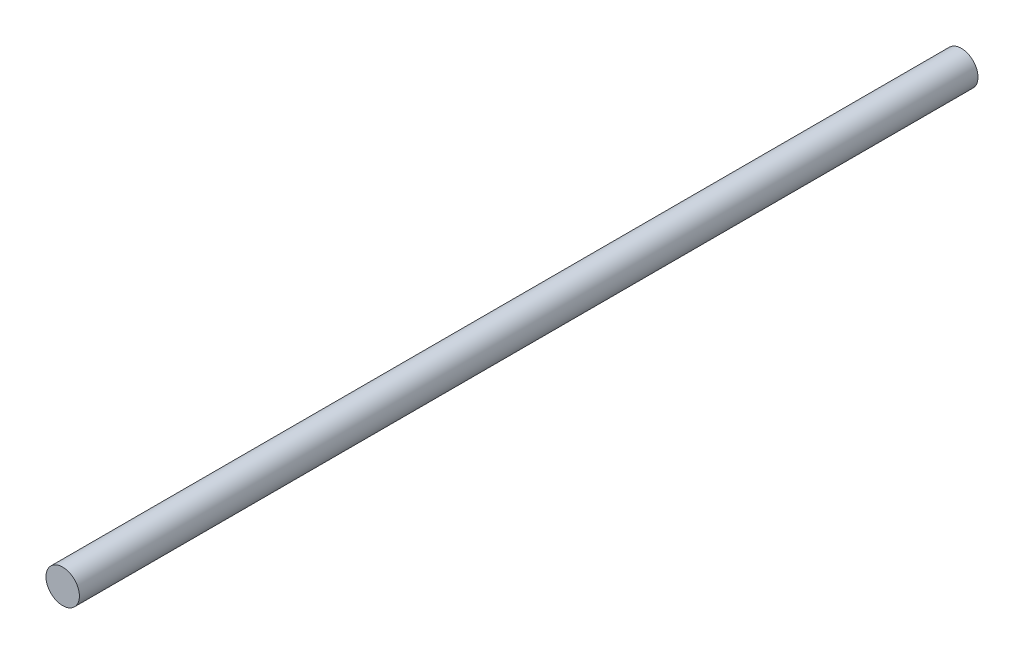
from build123d import *

# Parameters (mm, degrees)
SKETCH1_R                 = 4
BOSS_EXTRUDE1_DEPTH       = 215
M4X0_7_TAPPED_HOLE2_D     = 3.3
M4X0_7_TAPPED_HOLE2_DEPTH = 10.1
M4X0_7_TAPPED_HOLE2_TIP   = 0.991420021


with BuildPart() as part:
    # Sketch1 → Boss-Extrude1 (new body)
    with BuildSketch(Plane.XY):
        Circle(SKETCH1_R)
    extrude(amount=BOSS_EXTRUDE1_DEPTH)

    # M4x0.7 Tapped Hole2
    with Locations(Plane(origin=(0, 0, 0), x_dir=(-1, 0, 0), z_dir=(0, 0, -1))):
        with Locations((0, 0)):
            Hole(M4X0_7_TAPPED_HOLE2_D / 2, depth=M4X0_7_TAPPED_HOLE2_DEPTH)
            with Locations((0, 0, -(M4X0_7_TAPPED_HOLE2_DEPTH + M4X0_7_TAPPED_HOLE2_TIP / 2))):  # 118° drill point
                Cone(0, M4X0_7_TAPPED_HOLE2_D / 2, M4X0_7_TAPPED_HOLE2_TIP, mode=Mode.SUBTRACT)


solid = part.part
